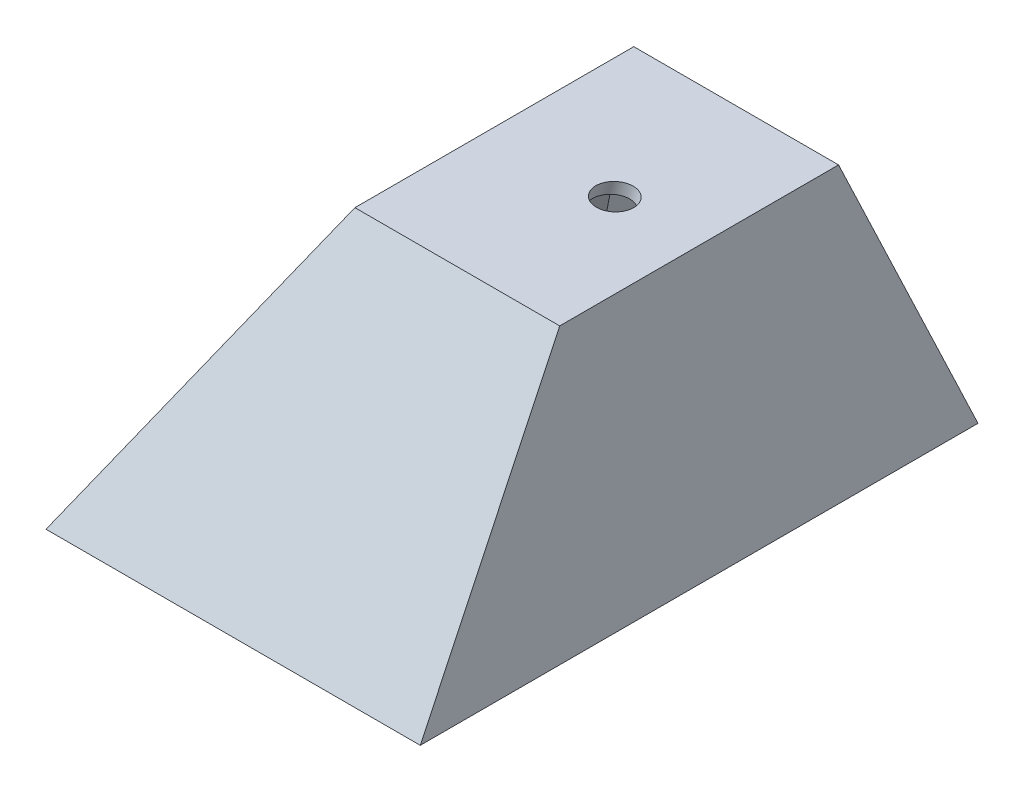
from build123d import *

# Parameters (mm, degrees)
EXTRUDE_1_DEPTH     = 76
CUT_EXTRUDE_1_DEPTH = 98.088188339
SHELL_2_T           = -1.75
SKETCH_7_R          = 2.5
CUT_EXTRUDE_3_DEPTH = 96.132124654
CUT_EXTRUDE_START   = 3
SKETCH_7_2_R        = 2.5
CUT_EXTRUDE_4_DEPTH = 3


with BuildPart() as part:
    # ｽｹｯﾁ1 → ﾎﾞｽ - 押し出し1 (new body)
    with BuildSketch(Plane.XY):
        Polygon((-16.411750997, 7.609934935), (-39.505761764, -32.390065065), (11.494238236, -32.390065065), (11.494238236, 7.609934935), align=None)
    extrude(amount=EXTRUDE_1_DEPTH)

    # ｽｹｯﾁ2 → ｶｯﾄ - 押し出し1 (cut, through all)
    with BuildSketch(Plane(origin=(11.494238236, 0, 0), x_dir=(0, 0, -1), z_dir=(1, 0, 0))):
        Polygon((-57, 7.609934935), (-76, -32.390065065), (-76, 7.609934935), align=None)
        Polygon((-19, 7.609934935), (0, -32.390065065), (0, 7.609934935), align=None)
    extrude(amount=-CUT_EXTRUDE_1_DEPTH, mode=Mode.SUBTRACT)

    # ｼｪﾙ2
    shell_2_openings = [part.faces().sort_by_distance(p)[0] for p in [
        (-14.005761764, -32.390065065, 38),
    ]]
    offset(amount=SHELL_2_T, openings=shell_2_openings, kind=Kind.INTERSECTION)

    # ｽｹｯﾁ7 → ｶｯﾄ - 押し出し3 (cut, through all)
    with BuildSketch(Plane(origin=(1.902483734, 7.100165955, 0), x_dir=(0.9659258262890676, -0.2588190451025229, 0), z_dir=(0.25881904510252296, 0.9659258262890678, 0))):
        with Locations((-1.969596093, -38)):
            Circle(SKETCH_7_R)
    extrude(amount=-CUT_EXTRUDE_3_DEPTH, mode=Mode.SUBTRACT)

    # ｽｹｯﾁ7<2> → ｶｯﾄ - 押し出し4 (cut)
    with BuildSketch(Plane(origin=(1.902483734, 7.100165955, 0), x_dir=(0.9659258262890676, -0.2588190451025229, 0), z_dir=(0.25881904510252296, 0.9659258262890678, 0)).offset(CUT_EXTRUDE_START)):
        with Locations((-1.969596093, -38)):
            Circle(SKETCH_7_2_R)
    extrude(amount=-CUT_EXTRUDE_4_DEPTH, mode=Mode.SUBTRACT)


solid = part.part
